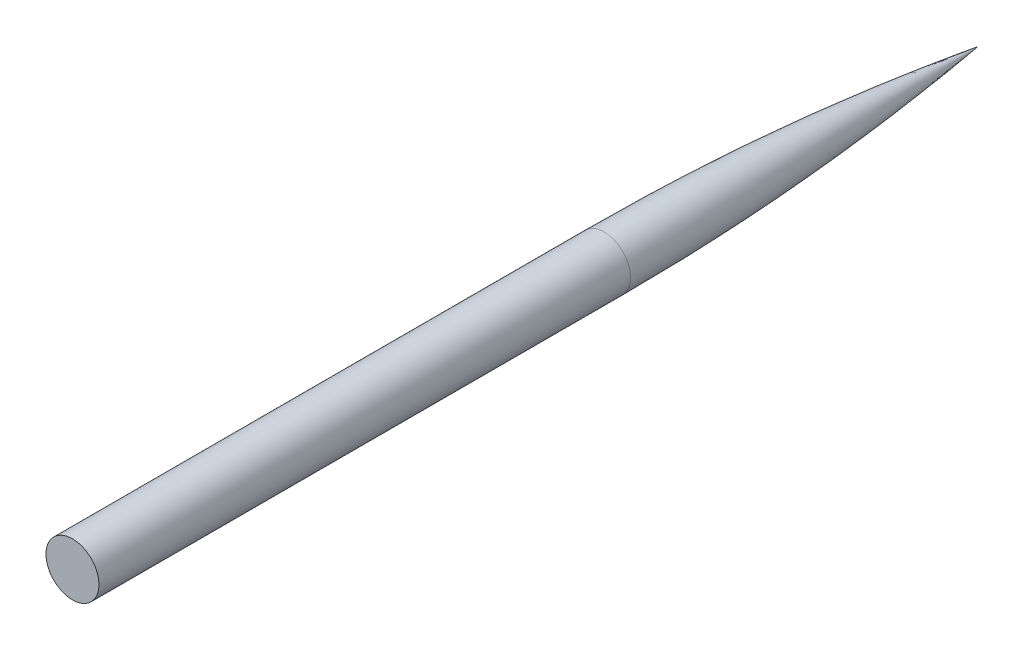
from build123d import *


with BuildPart() as part:
    # Sketch1 → Revolve2 (revolve)
    with BuildSketch(Plane(origin=(0, 0, 0), x_dir=(1, 0, 0), z_dir=(0, 1, 0))):
        with BuildLine():
            Line((0, -25), (2.49, -25))
            Line((2.49, -25), (2.49, 25))
            ThreePointArc((2.49, 25), (1.866722073, 42.631201005), (0, 60.174378396))
            Line((0, 60.174378396), (0, -25))
        make_face()
    revolve(axis=Axis((0, 0, -60.174378396), (0, 0, 1)))


solid = part.part
